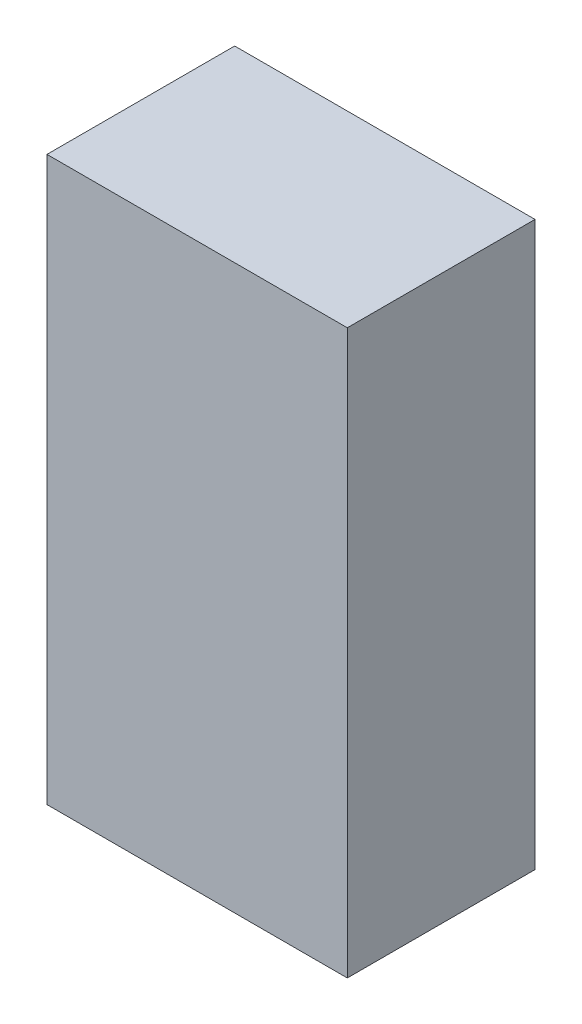
from build123d import *

# Parameters (mm, degrees)
SKICA1_W                = 8
SKICA1_H                = 15
P_IDAT_VYSUNUT_M1_DEPTH = 5


with BuildPart() as part:
    # Skica1 → Přidat vysunutím1 (new body)
    with BuildSketch(Plane.XY):
        Rectangle(SKICA1_W, SKICA1_H)
    extrude(amount=P_IDAT_VYSUNUT_M1_DEPTH)


solid = part.part
